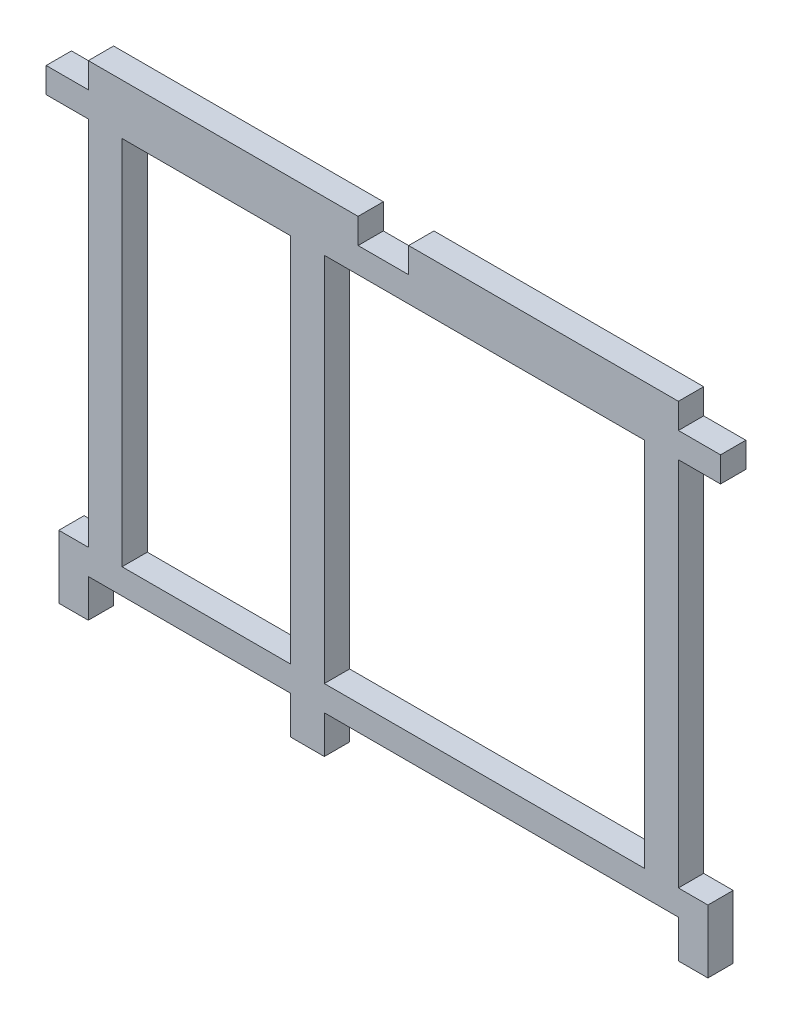
from build123d import *

# Parameters (mm, degrees)
SKETCH1_W           = 20
SKETCH1_H           = 44
SKETCH1_W_2         = 38
BOSS_EXTRUDE1_DEPTH = 3


with BuildPart() as part:
    # Sketch1 → Boss-Extrude1 (new body)
    with BuildSketch(Plane.XY):
        Polygon((5, -3), (0, -3), (0, 0), (5, 0), (5, 3), (37, 3), (37, 0), (43, 0), (43, 3), (75, 3), (75, 0), (80, 0), (80, -3), (75, -3), (75, -47), (78.5, -47), (78.5, -54.5), (75, -54.5), (75, -50), (33, -50), (33, -54.5), (29, -54.5), (29, -50), (5, -50), (5, -54.5), (1.5, -54.5), (1.5, -47), (5, -47), align=None)
        with Locations((19, -25)):
            Rectangle(SKETCH1_W, SKETCH1_H, mode=Mode.SUBTRACT)
        with Locations((52, -25)):
            Rectangle(SKETCH1_W_2, SKETCH1_H, mode=Mode.SUBTRACT)
    extrude(amount=BOSS_EXTRUDE1_DEPTH)


solid = part.part
